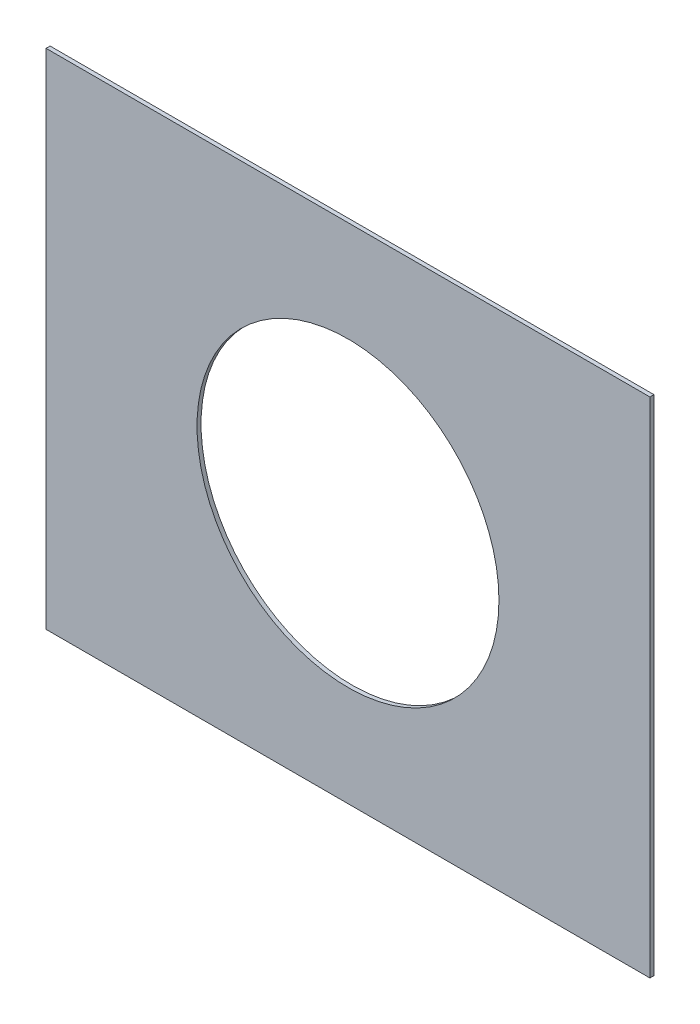
from build123d import *

# Parameters (mm, degrees)
SKETCH1_W           = 300
SKETCH1_H           = 250
SKETCH1_R           = 75
BOSS_EXTRUDE1_DEPTH = 2


with BuildPart() as part:
    # Sketch1 → Boss-Extrude1 (new body)
    with BuildSketch(Plane.XY):
        Rectangle(SKETCH1_W, SKETCH1_H)
        Circle(SKETCH1_R, mode=Mode.SUBTRACT)
    extrude(amount=BOSS_EXTRUDE1_DEPTH)


solid = part.part
